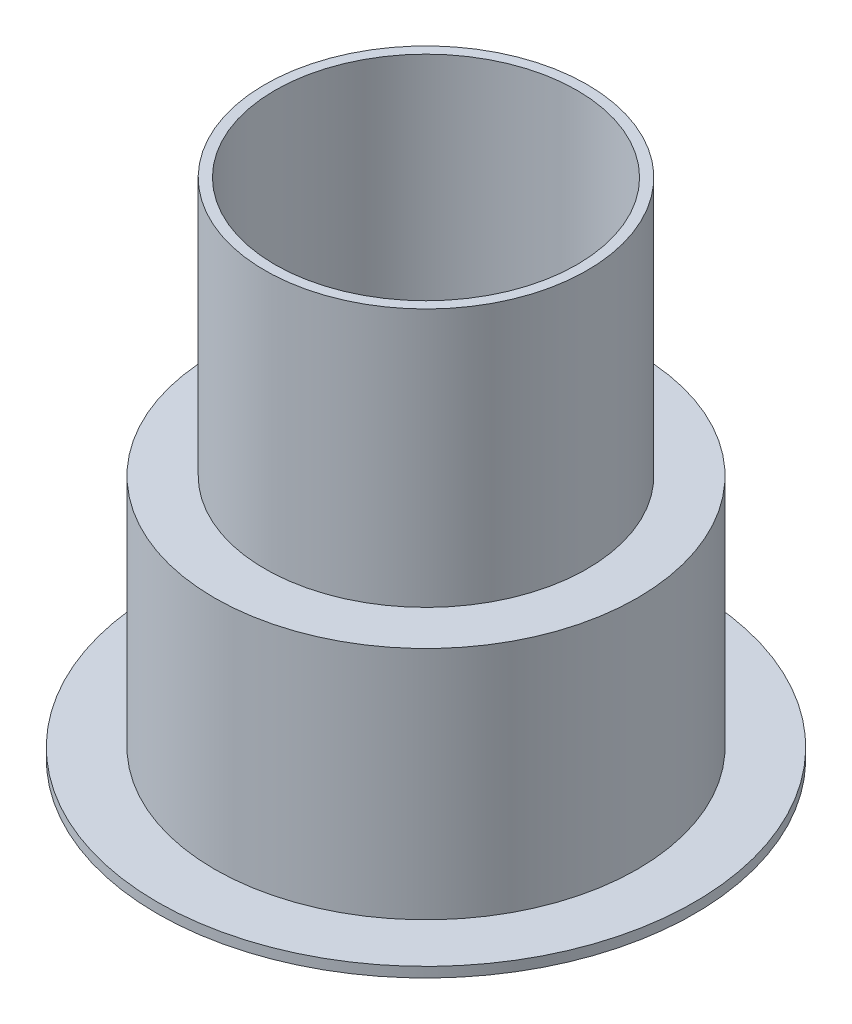
from build123d import *


with BuildPart() as part:
    # Sketch1 → Revolve1 (revolve)
    with BuildSketch(Plane.XY):
        Polygon((6, -0.854835863), (6, 6.145164137), (0, 6.145164137), (0, 6.445164137), (4.5, 6.445164137), (4.5, 14.145164137), (4.8, 14.145164137), (4.8, 6.445164137), (6.3, 6.445164137), (6.3, -0.554835863), (8, -0.554835863), (8, -0.854835863), align=None)
    revolve(axis=Axis((0, 0, 0), (0, 1, 0)))


solid = part.part
